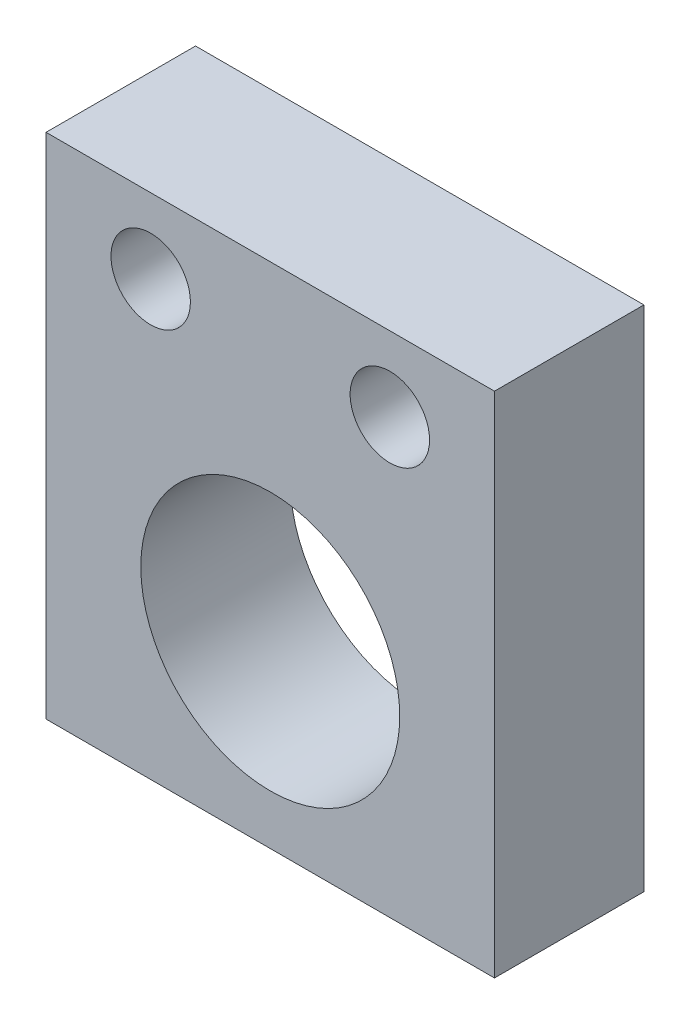
from build123d import *

# Parameters (mm, degrees)
SKETCH1_W                        = 38.1
SKETCH1_H                        = 43.18
BOSS_EXTRUDE1_DEPTH              = 12.7
SKETCH3_R                        = 11
CUT_EXTRUDE1_DEPTH               = 13.7
F_17_64_0_26563_DIAMETER_HOLE1_D = 6.747002
F_1_4_20_TAPPED_HOLE2_D          = 5.1054
F_1_4_20_TAPPED_HOLE2_DEPTH      = 12.7
F_1_4_20_TAPPED_HOLE2_TIP        = 1.533816902


with BuildPart() as part:
    # Sketch1 → Boss-Extrude1 (new body)
    with BuildSketch(Plane.XY):
        with Locations((19.05, 21.59)):
            Rectangle(SKETCH1_W, SKETCH1_H)
    extrude(amount=-BOSS_EXTRUDE1_DEPTH)

    # Sketch3 → Cut-Extrude1 (cut, through all)
    with BuildSketch(Plane.XY):
        with Locations((19.05, 15.24)):
            Circle(SKETCH3_R)
    extrude(amount=-CUT_EXTRUDE1_DEPTH, mode=Mode.SUBTRACT)

    # 17/64 (0.26563) Diameter Hole1 (through all)
    with Locations(Plane(origin=(29.21, 36.83, 0), x_dir=(1, 0, 0), z_dir=(0, 0, 1))):
        with Locations((0, 0), (-20.32, 0)):
            Hole(F_17_64_0_26563_DIAMETER_HOLE1_D / 2)

    # 1/4-20 Tapped Hole2
    with Locations(Plane(origin=(0, 27.94, -6.35), x_dir=(0, 0, -1), z_dir=(-1, 0, 0))):
        with Locations((0, 0)):
            Hole(F_1_4_20_TAPPED_HOLE2_D / 2, depth=F_1_4_20_TAPPED_HOLE2_DEPTH)
            with Locations((0, 0, -(F_1_4_20_TAPPED_HOLE2_DEPTH + F_1_4_20_TAPPED_HOLE2_TIP / 2))):  # 118° drill point
                Cone(0, F_1_4_20_TAPPED_HOLE2_D / 2, F_1_4_20_TAPPED_HOLE2_TIP, mode=Mode.SUBTRACT)


solid = part.part
